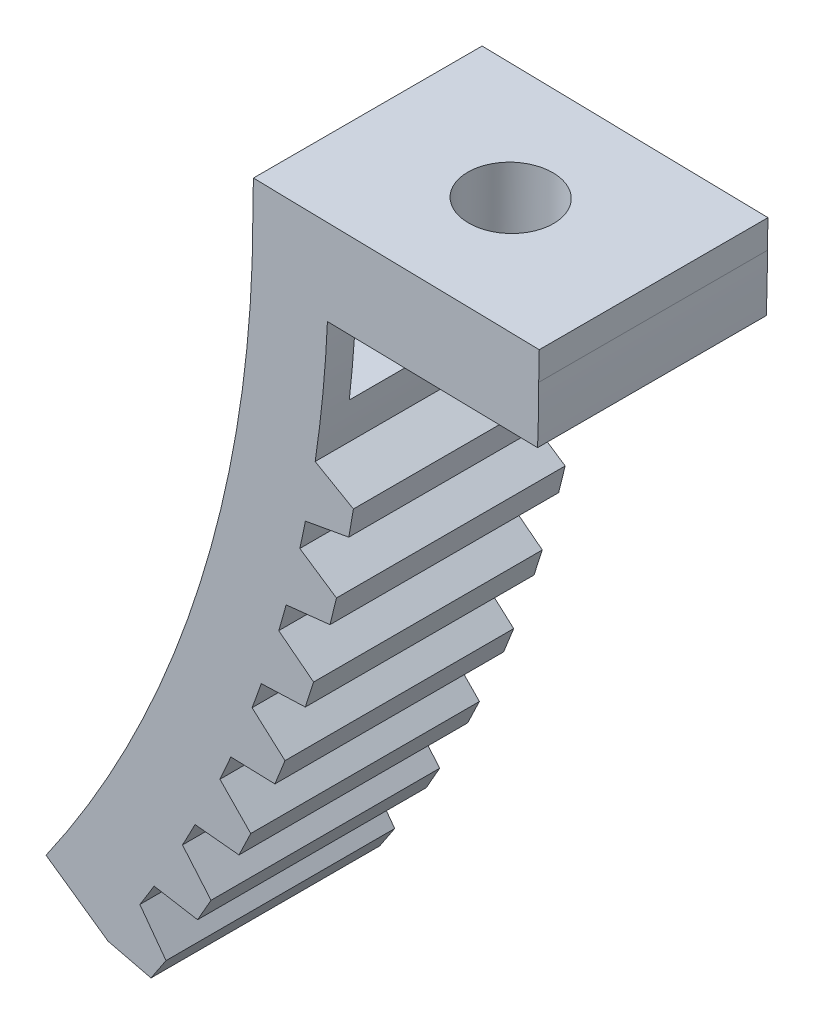
from build123d import *

# Parameters (mm, degrees)
EXTRUDE1_DEPTH    = 8
EXTRUDE5_DEPTH    = 8
SKETCH4_W         = 10.001997138
SKETCH4_H         = 8
EXTRUDE6_DEPTH    = 1
SKETCH2_R         = 1.5
EXTRUDE2_DEPTH    = 3
EXTRUDE7_DEPTH    = 9
SKETCH6_W         = 4.34249483
SKETCH6_H         = 6
EXTRUDE8_DEPTH    = 3
EXTRUDE9_DEPTH    = 8
CIRPATTERN1_COUNT = 7
CIRPATTERN1_ANGLE = 23.8


with BuildPart() as part:
    # Sketch1 → Extrude1 (new body)
    with BuildSketch(Plane.XY):
        with BuildLine():
            Line((0, 0), (-10, 0))
            ThreePointArc((-10, 0), (-11.85132197, -12.02823198), (-17.233918228, -22.943057454))
            Line((-17.233918228, -22.943057454), (-9.042397786, -28.678821818))
            ThreePointArc((-9.042397786, -28.678821818), (-2.314152463, -15.035289975), (0, 0))
        make_face()
    extrude(amount=EXTRUDE1_DEPTH)

    # Sketch3 → Extrude5 (add)
    with BuildSketch(Plane.XY):
        Polygon((-10, 0), (-10, 0.199866806), (0, 0), align=None)
    extrude(amount=EXTRUDE5_DEPTH)

    # Sketch4 → Extrude6 (add)
    with BuildSketch(Plane(origin=(0, 0, 0), x_dir=(-0.999800326, 0.01998269, 0), z_dir=(0.01998269, 0.999800326, 0))):
        with Locations((5.000998569, 4)):
            Rectangle(SKETCH4_W, SKETCH4_H)
    extrude(amount=EXTRUDE6_DEPTH)

    # Sketch2 → Extrude2 (cut)
    with BuildSketch(Plane(origin=(0.01998269, 0.999800326, 0), x_dir=(0.999800326, -0.01998269, 0), z_dir=(-0.01998269, -0.999800326, 0))):
        with Locations((-5.000998569, 4)):
            Circle(SKETCH2_R)
    extrude(amount=EXTRUDE2_DEPTH, mode=Mode.SUBTRACT)

    # Sketch5 → Extrude7 (cut, through all)
    with BuildSketch(Plane.XY.offset(8)):
        with BuildLine():
            Line((-0.04, -1.99959996), (-7.39025898, -1.852692681))
            ThreePointArc((-7.39025898, -1.852692681), (-9.612195577, -13.705756232), (-15.063165311, -24.46303501))
            Line((-15.063165311, -24.46303501), (-9.042397786, -28.678821818))
            Line((-9.042397786, -28.678821818), (-2.903131431, -26.123748854))
            Line((-2.903131431, -26.123748854), (1.597548849, -2.850180748))
            Line((1.597548849, -2.850180748), (-0.04, -1.99959996))
        make_face()
    extrude(amount=-EXTRUDE7_DEPTH, mode=Mode.SUBTRACT)

    # Sketch6 → Extrude8 (cut)
    with BuildSketch(Plane(origin=(-0.03996538, -1.999600652, 0), x_dir=(0.999800326, -0.01998269, 0), z_dir=(-0.01998269, -0.999800326, 0))):
        with Locations((-9.52300897, 4)):
            Rectangle(SKETCH6_W, SKETCH6_H)
    extrude(amount=EXTRUDE8_DEPTH, mode=Mode.SUBTRACT)

    # Sketch7 → Extrude9 (add)
    with BuildSketch(Plane.XY.offset(8)):
        Polygon((-15.063165311, -24.46303501), (-13.5637082, -24.827254247), (-13.037257571, -24.036463671), (-13.951792747, -22.793623096), align=None)
    extrude9 = extrude(amount=-EXTRUDE9_DEPTH)

    # CirPattern1: Extrude9 ×7 about axis
    cirpattern1_axis = Axis((-50, 0, 0), (0, 0, 1))
    for i in range(1, CIRPATTERN1_COUNT):
        add(extrude9.rotate(cirpattern1_axis, i * CIRPATTERN1_ANGLE / (CIRPATTERN1_COUNT - 1)))


solid = part.part
